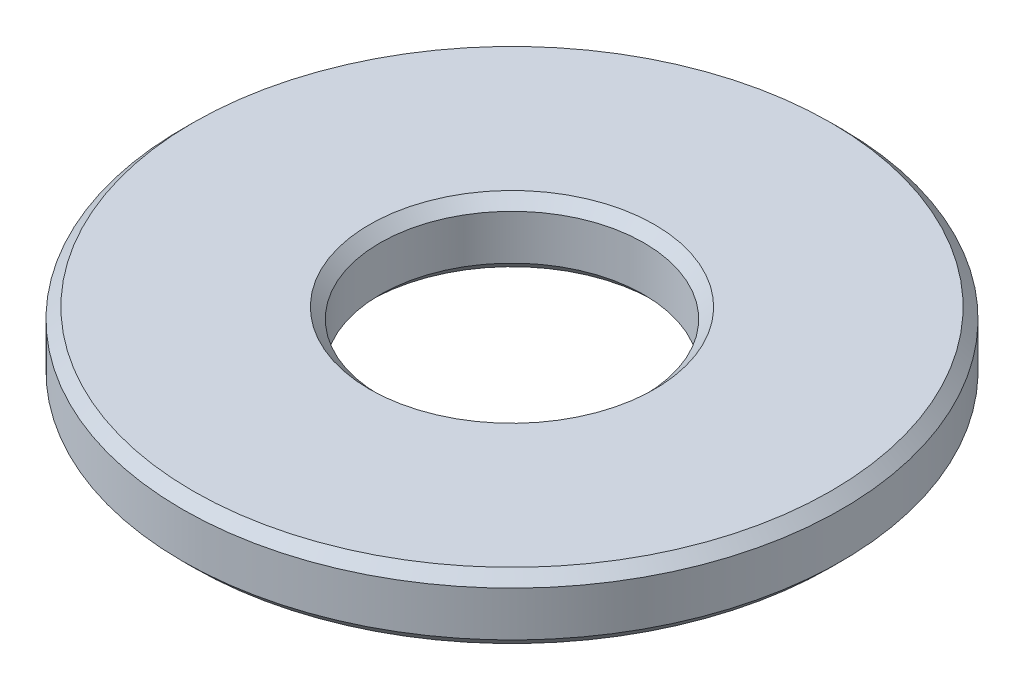
from build123d import *

# Parameters (mm, degrees)
SKETCH1_W     = 2.3749
SKETCH1_H     = 0.79375
CHAMFER1_SIZE = 0.127


with BuildPart() as part:
    # Sketch1 → Revolve1 (revolve)
    with BuildSketch(Plane.XY):
        with Locations((2.77495, 0)):
            Rectangle(SKETCH1_W, SKETCH1_H)
    revolve(axis=Axis((0, 3.40958908, 0), (0, -1, 0)))

    # Chamfer1
    chamfer1_edges = [part.edges().sort_by_distance(p)[0] for p in [
        (-3.9624, 0.396875, 0),
        (-3.9624, -0.396875, 0),
        (-1.5875, -0.396875, 0),
        (-1.5875, 0.396875, 0),
    ]]
    chamfer(chamfer1_edges, length=CHAMFER1_SIZE)


solid = part.part
